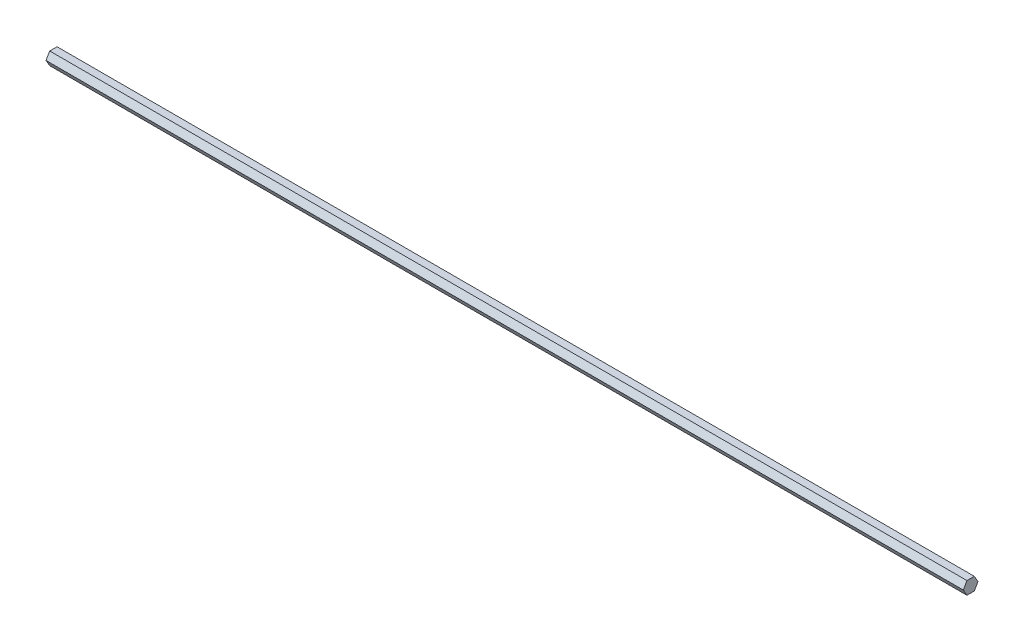
from build123d import *

# Parameters (mm, degrees)
BOSS_EXTRUDE1_DEPTH = 914.4


with BuildPart() as part:
    # Sketch1 → Boss-Extrude1 (new body)
    with BuildSketch(Plane(origin=(0, 0, 0), x_dir=(0, 0, -1), z_dir=(1, 0, 0))):
        Polygon((7.332348419, 0), (3.666174209, 6.35), (-3.666174209, 6.35), (-7.332348419, 0), (-3.666174209, -6.35), (3.666174209, -6.35), align=None)
    extrude(amount=BOSS_EXTRUDE1_DEPTH)


solid = part.part
